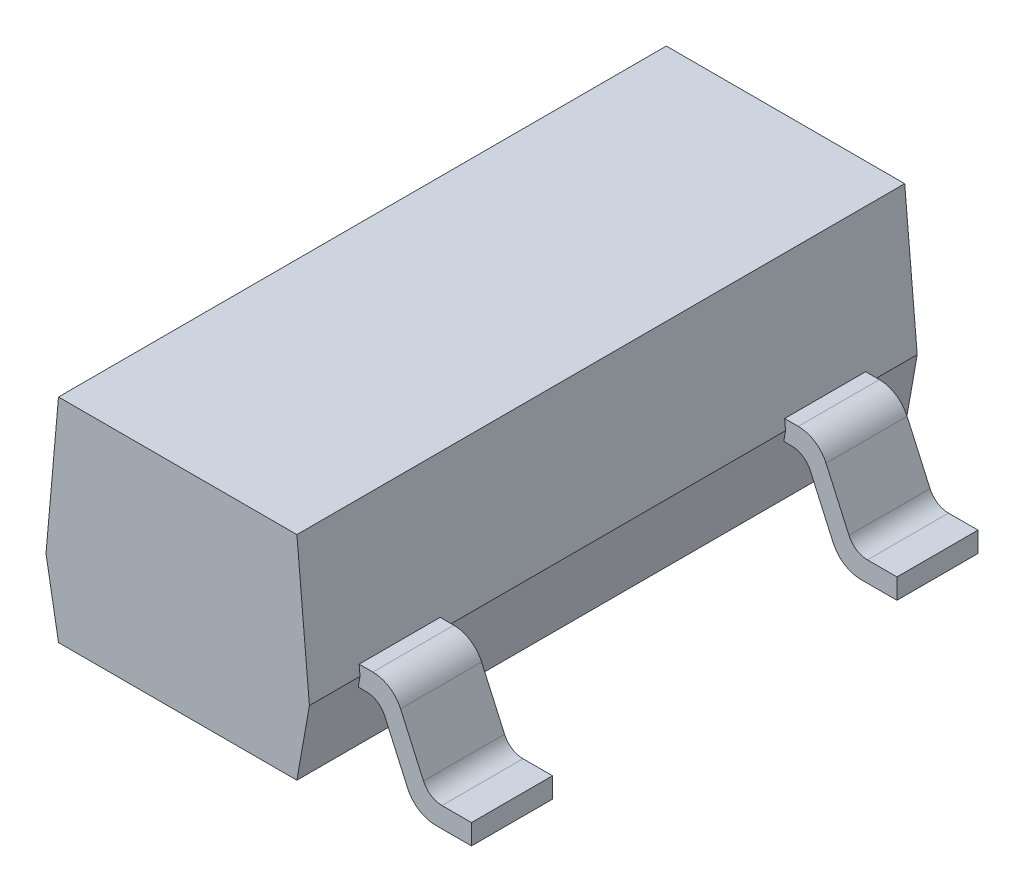
from build123d import *

# Parameters (mm, degrees)
EXTRUDE1_DEPTH     = 1.5
EXTRUDE2_DEPTH     = 0.2
EXTRUDE5_DEPTH     = 0.2
EXTRUDE6_DEPTH     = 0.2
FILLET2_R          = 0.1
SKETCH14_W         = 0.020253164
SKETCH14_H         = 0.021265823
SKETCH14_W_2       = 0.020253165
CUT_EXTRUDE1_DEPTH = 0.01


with BuildPart() as part:
    # Sketch1 → Extrude1 (new body, symmetric)
    with BuildSketch(Plane.XY):
        Polygon((0.588285557, 0.525), (-0.588285557, 0.525), (-0.65, -0.175), (-0.588285557, -0.525), (0.588285557, -0.525), (0.65, -0.175), align=None)
    extrude(amount=EXTRUDE1_DEPTH, both=True)

    # Sketch2 → Extrude2 (add, symmetric)
    with BuildSketch(Plane.XY.offset(1.05)):
        with BuildLine():
            Line((0.713146135, -0.125), (0.5, -0.125))
            Line((0.5, -0.125), (0.5, -0.225))
            Line((0.5, -0.225), (0.745513278, -0.225))
            Line((0.745513278, -0.225), (0.885247563, -0.536408629))
            ThreePointArc((0.885247563, -0.536408629), (0.940588528, -0.600919209), (1.022101428, -0.625))
            Line((1.022101428, -0.625), (1.2, -0.625))
            Line((1.2, -0.625), (1.2, -0.525))
            Line((1.2, -0.525), (1.05446857, -0.525))
            ThreePointArc((1.05446857, -0.525), (1.000126637, -0.508946139), (0.96323266, -0.465939086))
            Line((0.96323266, -0.465939086), (0.85, -0.213591371))
            ThreePointArc((0.85, -0.213591371), (0.794659035, -0.149080791), (0.713146135, -0.125))
        make_face()
    extrude(amount=EXTRUDE2_DEPTH, both=True)

    # Sketch12 → Extrude5 (add, symmetric)
    with BuildSketch(Plane.XY.offset(-1.05)):
        with BuildLine():
            Line((1.022101428, -0.625), (1.2, -0.625))
            Line((1.2, -0.625), (1.2, -0.525))
            Line((1.2, -0.525), (1.05446857, -0.525))
            ThreePointArc((1.05446857, -0.525), (1.000126637, -0.508946139), (0.96323266, -0.465939086))
            Line((0.96323266, -0.465939086), (0.85, -0.213591371))
            ThreePointArc((0.85, -0.213591371), (0.794659035, -0.149080791), (0.713146135, -0.125))
            Line((0.713146135, -0.125), (0.5, -0.125))
            Line((0.5, -0.125), (0.5, -0.225))
            Line((0.5, -0.225), (0.745513278, -0.225))
            Line((0.745513278, -0.225), (0.885247563, -0.536408629))
            ThreePointArc((0.885247563, -0.536408629), (0.940588528, -0.600919209), (1.022101428, -0.625))
        make_face()
    extrude(amount=EXTRUDE5_DEPTH, both=True)

    # Sketch13 → Extrude6 (add, symmetric)
    with BuildSketch(Plane.XY):
        with BuildLine():
            Line((-1.2, -0.625), (-1.022101428, -0.625))
            ThreePointArc((-1.022101428, -0.625), (-0.940588528, -0.600919209), (-0.885247563, -0.536408629))
            Line((-0.885247563, -0.536408629), (-0.745513278, -0.225))
            Line((-0.745513278, -0.225), (-0.5, -0.225))
            Line((-0.5, -0.225), (-0.5, -0.125))
            Line((-0.5, -0.125), (-0.713146135, -0.125))
            ThreePointArc((-0.713146135, -0.125), (-0.794659035, -0.149080791), (-0.85, -0.213591371))
            Line((-0.85, -0.213591371), (-0.96323266, -0.465939086))
            ThreePointArc((-0.96323266, -0.465939086), (-1.000126637, -0.508946139), (-1.05446857, -0.525))
            Line((-1.05446857, -0.525), (-1.2, -0.525))
            Line((-1.2, -0.525), (-1.2, -0.625))
        make_face()
    extrude(amount=EXTRUDE6_DEPTH, both=True)

    # Fillet2
    fillet2_edges = [part.edges().sort_by_distance(p)[0] for p in [
        (0.745513278, -0.225, 1.05),
        (0.745513278, -0.225, -1.05),
        (-0.745513278, -0.225, 0),
    ]]
    fillet(fillet2_edges, radius=FILLET2_R)

    # Sketch14 → Cut-Extrude1 (cut)
    with BuildSketch(Plane.XZ.offset(0.525)):
        Polygon((0.467126587, 1.30364904), (0.48589241, 1.363395875), (0.505686714, 1.363395875), (0.518819625, 1.323126888), (0.531240511, 1.363395875), (0.551825954, 1.363395875), (0.570417726, 1.30364904), (0.550275321, 1.30364904), (0.539879752, 1.344835749), (0.52674684, 1.30364904), (0.509547473, 1.30364904), (0.496493676, 1.344835749), (0.486240511, 1.30364904), align=None)
        Polygon((0.359784815, 1.30364904), (0.378550638, 1.363395875), (0.398344942, 1.363395875), (0.411477853, 1.323126888), (0.423898739, 1.363395875), (0.444484182, 1.363395875), (0.463075954, 1.30364904), (0.442933549, 1.30364904), (0.43253798, 1.344835749), (0.419405068, 1.30364904), (0.402205701, 1.30364904), (0.389151904, 1.344835749), (0.378898739, 1.30364904), align=None)
        Polygon((0.252443043, 1.30364904), (0.271208866, 1.363395875), (0.291003169, 1.363395875), (0.304136081, 1.323126888), (0.316556967, 1.363395875), (0.33714241, 1.363395875), (0.355734182, 1.30364904), (0.335591777, 1.30364904), (0.325196207, 1.344835749), (0.312063296, 1.30364904), (0.294863929, 1.30364904), (0.281810132, 1.344835749), (0.271556967, 1.30364904), align=None)
        with Locations((0.230164562, 1.352762964)):
            Rectangle(SKETCH14_W, SKETCH14_H)
        with BuildLine():
            add(Edge.make_bspline(
                [(0.137000005, 1.338459166), (0.137029227, 1.339436858), (0.137086611, 1.341356717), (0.13757394, 1.34416309), (0.13837036, 1.346821716), (0.13946183, 1.349351889), (0.140913021, 1.351716182), (0.142637031, 1.353971035), (0.144726563, 1.356038205), (0.147076192, 1.357989214), (0.149714534, 1.359735129), (0.152596631, 1.36125524), (0.155692887, 1.362555015), (0.159016104, 1.363620367), (0.162572566, 1.364412981), (0.166346787, 1.364991634), (0.170341466, 1.365370441), (0.173080337, 1.365403994), (0.174484182, 1.365421192)],
                knots=[0, 0, 0, 0, 0.907421153, 1.781872267, 2.635683434, 3.480115191, 4.332689235, 5.205575272, 6.109500117, 7.055808355, 8.037942167, 9.041423561, 10.07750834, 11.152467461, 12.277657752, 13.45734338, 14.696726425, 16, 16, 16, 16], degree=3))
            add(Edge.make_bspline(
                [(0.174484182, 1.365421192), (0.17609857, 1.36539938), (0.179225119, 1.365357137), (0.183759173, 1.365048838), (0.187969946, 1.364498479), (0.191888144, 1.363733214), (0.195571585, 1.362770586), (0.19911826, 1.361738071), (0.202543294, 1.360566407), (0.204761768, 1.359686298), (0.205860764, 1.359250306)],
                knots=[0, 0, 0, 0, 1.203182053, 2.33017619, 3.384818652, 4.366208123, 5.30340534, 6.221361684, 7.118890722, 8, 8, 8, 8], degree=3))
            Line((0.205860764, 1.359250306), (0.205860764, 1.340104736))
            Line((0.205860764, 1.340104736), (0.203582283, 1.340104736))
            add(Edge.make_bspline(
                [(0.203582283, 1.340104736), (0.202489833, 1.340969506), (0.200311345, 1.342693969), (0.196769779, 1.344908653), (0.193042569, 1.346807061), (0.189171854, 1.348393159), (0.185250759, 1.349653651), (0.181355505, 1.350555175), (0.177540319, 1.351146667), (0.175013662, 1.351211916), (0.173772157, 1.351243976)],
                knots=[0, 0, 0, 0, 1.030738938, 2.055426519, 3.085610749, 4.123842265, 5.148648843, 6.130724483, 7.081507926, 8, 8, 8, 8], degree=3))
            add(Edge.make_bspline(
                [(0.173772157, 1.351243976), (0.17342916, 1.351242936), (0.17269483, 1.351240708), (0.171519512, 1.351143656), (0.170194437, 1.351041381), (0.168769846, 1.350884489), (0.167340082, 1.350699574), (0.166011884, 1.3504224), (0.164811275, 1.350127079), (0.164085939, 1.349833266), (0.163740511, 1.349693344)],
                knots=[0, 0, 0, 0, 0.806537132, 1.726733348, 2.77251655, 3.932999672, 5.098049949, 6.161349231, 7.124375527, 8, 8, 8, 8], degree=3))
            add(Edge.make_bspline(
                [(0.163740511, 1.349693344), (0.163356922, 1.349510755), (0.162603088, 1.34915193), (0.161561064, 1.348500802), (0.160624676, 1.347785006), (0.159776114, 1.347015619), (0.159086197, 1.346085229), (0.158589269, 1.344965812), (0.158313612, 1.343646378), (0.158282355, 1.342706248), (0.158265828, 1.342209166)],
                knots=[0, 0, 0, 0, 1.02474257, 2.013837243, 2.958431669, 3.867978675, 4.769292696, 5.732237074, 6.800947934, 8, 8, 8, 8], degree=3))
            add(Edge.make_bspline(
                [(0.158265828, 1.342209166), (0.158290997, 1.341772473), (0.158340487, 1.340913806), (0.158805691, 1.339691063), (0.159512929, 1.338554954), (0.160536461, 1.337542685), (0.161827404, 1.336641795), (0.163372194, 1.335833184), (0.165191274, 1.335164579), (0.166501044, 1.334814281), (0.167189878, 1.334630052)],
                knots=[0, 0, 0, 0, 0.825427492, 1.623033598, 2.45033906, 3.348940377, 4.33183287, 5.428402891, 6.647546779, 8, 8, 8, 8], degree=3))
            add(Edge.make_bspline(
                [(0.167189878, 1.334630052), (0.168765271, 1.334273889), (0.17199344, 1.333544066), (0.176905291, 1.332594103), (0.181816253, 1.331613406), (0.184981258, 1.330641954), (0.186525321, 1.330168027)],
                knots=[0, 0, 0, 0, 0.976118991, 2.000185432, 3.024380873, 4, 4, 4, 4], degree=3))
            add(Edge.make_bspline(
                [(0.186525321, 1.330168027), (0.187355844, 1.329885049), (0.188972533, 1.329334205), (0.191291887, 1.328412087), (0.193406485, 1.327367979), (0.195372516, 1.326310349), (0.197126647, 1.325126303), (0.198722354, 1.323900095), (0.200124483, 1.322577851), (0.201345633, 1.321178258), (0.202419926, 1.319709168), (0.203342653, 1.318151455), (0.204111472, 1.316498295), (0.204770185, 1.314773978), (0.205259166, 1.312954349), (0.205597115, 1.311053216), (0.205835566, 1.309066427), (0.205852251, 1.307710958), (0.205860764, 1.307019293)],
                knots=[0, 0, 0, 0, 1.287376879, 2.505999703, 3.65855109, 4.746193839, 5.778582289, 6.760029101, 7.696159662, 8.601061861, 9.48181646, 10.363080883, 11.252765705, 12.153987336, 13.068239035, 14.012364187, 14.985753787, 16, 16, 16, 16], degree=3))
            add(Edge.make_bspline(
                [(0.205860764, 1.307019293), (0.205830924, 1.306094376), (0.205772199, 1.304274156), (0.205291039, 1.301610938), (0.20446983, 1.299091883), (0.203360743, 1.296689358), (0.201898748, 1.294437948), (0.20014505, 1.292295958), (0.198056802, 1.290301962), (0.19566854, 1.288463052), (0.193039062, 1.286800008), (0.190211858, 1.285330642), (0.187188777, 1.284125484), (0.184004869, 1.283100499), (0.180629355, 1.282338583), (0.177079779, 1.28176292), (0.173340689, 1.28143252), (0.17078756, 1.2813915), (0.169484182, 1.281370559)],
                knots=[0, 0, 0, 0, 0.894901293, 1.761149761, 2.608783409, 3.453876344, 4.314933854, 5.200038827, 6.12799933, 7.103249695, 8.113098521, 9.136064399, 10.182719798, 11.259667356, 12.370545059, 13.528828137, 14.738461593, 16, 16, 16, 16], degree=3))
            add(Edge.make_bspline(
                [(0.169484182, 1.281370559), (0.168149261, 1.281388473), (0.165481682, 1.281424271), (0.161496103, 1.281724247), (0.157530172, 1.282177448), (0.15363292, 1.282817011), (0.149886915, 1.283631136), (0.146353624, 1.284499902), (0.143090448, 1.285492214), (0.141031468, 1.28625545), (0.14003798, 1.286623723)],
                knots=[0, 0, 0, 0, 1.065379838, 2.128953261, 3.188461447, 4.250817766, 5.279613205, 6.247547721, 7.154416075, 8, 8, 8, 8], degree=3))
            Line((0.14003798, 1.286623723), (0.14003798, 1.304661698))
            Line((0.14003798, 1.304661698), (0.142300638, 1.304661698))
            add(Edge.make_bspline(
                [(0.142300638, 1.304661698), (0.143159005, 1.304021535), (0.14491439, 1.302712385), (0.147841392, 1.301043603), (0.15101264, 1.299483992), (0.154424561, 1.298106557), (0.158002594, 1.296970077), (0.161664631, 1.296146841), (0.165366282, 1.295635543), (0.167847555, 1.295577037), (0.169088613, 1.295547774)],
                knots=[0, 0, 0, 0, 0.89224925, 1.824673196, 2.804309561, 3.838364047, 4.890042674, 5.931526337, 6.965412421, 8, 8, 8, 8], degree=3))
            add(Edge.make_bspline(
                [(0.169088613, 1.295547774), (0.169964852, 1.295567142), (0.171716649, 1.295605862), (0.174336175, 1.295885265), (0.176924008, 1.296422659), (0.178558327, 1.297074128), (0.179373423, 1.29739904)],
                knots=[0, 0, 0, 0, 0.998993879, 1.997209027, 3.00113285, 4, 4, 4, 4], degree=3))
            add(Edge.make_bspline(
                [(0.179373423, 1.29739904), (0.179720206, 1.297560226), (0.180413542, 1.297882491), (0.181379144, 1.298500352), (0.182261787, 1.299244126), (0.183062592, 1.300086041), (0.183741036, 1.301021509), (0.184251164, 1.302037316), (0.18453982, 1.303126899), (0.184576489, 1.303874234), (0.184594942, 1.304250306)],
                knots=[0, 0, 0, 0, 1.005454979, 2.010239304, 3.005296729, 4.036100111, 5.060531193, 6.034954812, 7.011155677, 8, 8, 8, 8], degree=3))
            add(Edge.make_bspline(
                [(0.184594942, 1.304250306), (0.184567106, 1.30476065), (0.184513915, 1.305735873), (0.184033917, 1.30710683), (0.183235782, 1.308277319), (0.182313303, 1.309071714), (0.18141972, 1.309630722), (0.180587306, 1.310034913), (0.179627745, 1.310445652), (0.178525786, 1.310837009), (0.177297678, 1.311232247), (0.17593054, 1.311611982), (0.174424454, 1.31197163), (0.173371741, 1.312200551), (0.17282279, 1.312319926)],
                knots=[0, 0, 0, 0, 1.174343879, 2.244064321, 3.303704314, 4.407076671, 5.02483983, 5.732197225, 6.53898402, 7.431906431, 8.428480183, 9.514816237, 10.704066255, 12, 12, 12, 12], degree=3))
            add(Edge.make_bspline(
                [(0.17282279, 1.312319926), (0.17135669, 1.312621302), (0.168476128, 1.313213439), (0.164152068, 1.314088877), (0.159757624, 1.315138891), (0.156821184, 1.31604226), (0.155291144, 1.316512964)],
                knots=[0, 0, 0, 0, 0.995788186, 1.956503735, 2.935230479, 4, 4, 4, 4], degree=3))
            add(Edge.make_bspline(
                [(0.155291144, 1.316512964), (0.154533899, 1.316768357), (0.153052605, 1.317267947), (0.150940127, 1.318137002), (0.148982388, 1.319076087), (0.147169081, 1.320069663), (0.145508788, 1.32114361), (0.143999756, 1.322283876), (0.142641391, 1.323487702), (0.141450392, 1.324780278), (0.140387386, 1.326148557), (0.139497511, 1.327629047), (0.138701042, 1.32918387), (0.138098519, 1.330858625), (0.137598911, 1.332617447), (0.137261517, 1.334482995), (0.137026027, 1.336438369), (0.137008776, 1.337778048), (0.137000005, 1.338459166)],
                knots=[0, 0, 0, 0, 1.237326419, 2.420410185, 3.534642089, 4.598489486, 5.620241961, 6.59385002, 7.525152549, 8.426792174, 9.312230456, 10.203151844, 11.098070343, 12.012931196, 12.954244379, 13.926618287, 14.945853925, 16, 16, 16, 16], degree=3))
        make_face()
        with BuildLine():
            Line((0.063075954, 1.363395875), (0.082316461, 1.363395875))
            Line((0.082316461, 1.363395875), (0.082316461, 1.357130052))
            add(Edge.make_bspline(
                [(0.082316461, 1.357130052), (0.083191016, 1.357777088), (0.084877145, 1.359024564), (0.087416792, 1.360686213), (0.089831432, 1.362113751), (0.092175714, 1.363332245), (0.094580735, 1.364301982), (0.097171243, 1.364956686), (0.09997252, 1.365358865), (0.101914176, 1.365399954), (0.102917726, 1.365421192)],
                knots=[0, 0, 0, 0, 1.150945962, 2.219006967, 3.209666795, 4.118194914, 5.012574058, 5.946577101, 6.93868214, 8, 8, 8, 8], degree=3))
            add(Edge.make_bspline(
                [(0.102917726, 1.365421192), (0.103730746, 1.365402833), (0.105313931, 1.365367084), (0.107616571, 1.365093708), (0.109778144, 1.364654981), (0.111801213, 1.364040256), (0.113680973, 1.363237831), (0.115395917, 1.362220523), (0.116997979, 1.361074352), (0.118423536, 1.35970926), (0.119715973, 1.358190925), (0.12082203, 1.356484997), (0.121764194, 1.354618646), (0.122517074, 1.352577166), (0.123121145, 1.350370522), (0.123540291, 1.347987124), (0.123796765, 1.345437422), (0.123822316, 1.343681318), (0.123835448, 1.342778787)],
                knots=[0, 0, 0, 0, 1.108959949, 2.159465255, 3.158589008, 4.114545495, 5.039534357, 5.93921201, 6.830099133, 7.720870013, 8.624681761, 9.544731627, 10.487599671, 11.471264588, 12.508152322, 13.604835107, 14.769030043, 16, 16, 16, 16], degree=3))
            Line((0.123835448, 1.342778787), (0.123835448, 1.30364904))
            Line((0.123835448, 1.30364904), (0.104594942, 1.30364904))
            Line((0.104594942, 1.30364904), (0.104594942, 1.333712331))
            add(Edge.make_bspline(
                [(0.104594942, 1.333712331), (0.104593633, 1.334445508), (0.104591129, 1.33584888), (0.104525258, 1.337853525), (0.104428537, 1.339668063), (0.104317573, 1.341301686), (0.10411516, 1.342779087), (0.103812993, 1.344112016), (0.103436332, 1.345327697), (0.103064877, 1.346053059), (0.102886081, 1.346402204)],
                knots=[0, 0, 0, 0, 1.361401701, 2.605856924, 3.723918663, 4.735739235, 5.645738665, 6.489217889, 7.27279937, 8, 8, 8, 8], degree=3))
            add(Edge.make_bspline(
                [(0.102886081, 1.346402204), (0.102702074, 1.346721169), (0.102340333, 1.347348226), (0.101604121, 1.348153275), (0.100741047, 1.348828275), (0.099719284, 1.349354756), (0.098527631, 1.349747158), (0.097150944, 1.350051615), (0.09555755, 1.350189117), (0.094431576, 1.35021671), (0.093835448, 1.350231318)],
                knots=[0, 0, 0, 0, 0.849004071, 1.669068917, 2.503060811, 3.370079215, 4.310762265, 5.396376419, 6.621555549, 8, 8, 8, 8], degree=3))
            add(Edge.make_bspline(
                [(0.093835448, 1.350231318), (0.093402694, 1.350215447), (0.092513561, 1.350182838), (0.091139599, 1.350029605), (0.089708191, 1.349710278), (0.087693256, 1.349194322), (0.085161088, 1.348239239), (0.083273461, 1.347156721), (0.082316461, 1.3466079)],
                knots=[0, 0, 0, 0, 0.638062719, 1.310959128, 2.033463623, 2.796942592, 4.376095945, 6, 6, 6, 6], degree=3))
            Line((0.082316461, 1.3466079), (0.082316461, 1.30364904))
            Line((0.082316461, 1.30364904), (0.063075954, 1.30364904))
            Line((0.063075954, 1.30364904), (0.063075954, 1.363395875))
        make_face()
        with BuildLine():
            Line((-0.014898729, 1.363395875), (0.004341777, 1.363395875))
            Line((0.004341777, 1.363395875), (0.004341777, 1.333332584))
            add(Edge.make_bspline(
                [(0.004341777, 1.333332584), (0.004361782, 1.332108592), (0.00440176, 1.329662599), (0.004623, 1.326652124), (0.00493059, 1.324378892), (0.005224621, 1.322913621), (0.005570118, 1.321675128), (0.005899927, 1.320966519), (0.006050638, 1.320642711)],
                knots=[0, 0, 0, 0, 1.709111167, 3.415443484, 4.21113913, 4.910175115, 5.501990373, 6, 6, 6, 6], degree=3))
            add(Edge.make_bspline(
                [(0.006050638, 1.320642711), (0.006246207, 1.32032426), (0.006629646, 1.319699894), (0.007379527, 1.318889592), (0.008254554, 1.318226098), (0.009271495, 1.317682524), (0.010461982, 1.317299174), (0.011841116, 1.317016971), (0.013425264, 1.316848527), (0.014552326, 1.316825685), (0.015148739, 1.316813597)],
                knots=[0, 0, 0, 0, 0.860202684, 1.686548532, 2.528236983, 3.382486038, 4.33249885, 5.401154041, 6.624757403, 8, 8, 8, 8], degree=3))
            add(Edge.make_bspline(
                [(0.015148739, 1.316813597), (0.01605345, 1.316861677), (0.017899607, 1.31695979), (0.020199854, 1.317493123), (0.022053725, 1.318181095), (0.023539898, 1.318781443), (0.025066076, 1.319560724), (0.02608971, 1.320137877), (0.026620258, 1.320437014)],
                knots=[0, 0, 0, 0, 1.33818541, 2.730705359, 3.468371228, 4.262126284, 5.099261778, 6, 6, 6, 6], degree=3))
            Line((0.026620258, 1.320437014), (0.026620258, 1.363395875))
            Line((0.026620258, 1.363395875), (0.045860764, 1.363395875))
            Line((0.045860764, 1.363395875), (0.045860764, 1.30364904))
            Line((0.045860764, 1.30364904), (0.026620258, 1.30364904))
            Line((0.026620258, 1.30364904), (0.026620258, 1.309914863))
            add(Edge.make_bspline(
                [(0.026620258, 1.309914863), (0.025774333, 1.309269941), (0.024127689, 1.308014564), (0.021584299, 1.306382227), (0.019117181, 1.304943212), (0.016674773, 1.303732958), (0.014182809, 1.302767539), (0.011572602, 1.302118747), (0.008839477, 1.301683705), (0.006970105, 1.30164395), (0.006018992, 1.301623723)],
                knots=[0, 0, 0, 0, 1.126119141, 2.192057864, 3.198061997, 4.149848529, 5.076251285, 6.021887753, 6.99356175, 8, 8, 8, 8], degree=3))
            add(Edge.make_bspline(
                [(0.006018992, 1.301623723), (0.00522198, 1.301644044), (0.003666071, 1.301683712), (0.001398192, 1.301931354), (-0.000738694, 1.302372332), (-0.002733401, 1.303009018), (-0.00460195, 1.303802105), (-0.006340888, 1.304765288), (-0.007929567, 1.305935913), (-0.009392089, 1.307263864), (-0.010703369, 1.308776902), (-0.011820896, 1.310480405), (-0.012784386, 1.312349941), (-0.013543798, 1.314400051), (-0.014176857, 1.316613068), (-0.014580668, 1.319011972), (-0.01486679, 1.32157988), (-0.01488787, 1.3233528), (-0.014898729, 1.324266128)],
                knots=[0, 0, 0, 0, 1.08828964, 2.12453497, 3.110382522, 4.062402335, 4.978696626, 5.878225494, 6.769849763, 7.667011675, 8.57076823, 9.495541561, 10.442454184, 11.436213583, 12.475881554, 13.580560132, 14.753614518, 16, 16, 16, 16], degree=3))
            Line((-0.014898729, 1.324266128), (-0.014898729, 1.363395875))
        make_face()
        Polygon((-0.090848096, 1.363395875), (-0.033126577, 1.363395875), (-0.033126577, 1.283395875), (-0.053379742, 1.283395875), (-0.053379742, 1.348206002), (-0.090848096, 1.348206002), align=None)
        Polygon((-0.160721514, 1.363395875), (-0.102999995, 1.363395875), (-0.102999995, 1.283395875), (-0.160721514, 1.283395875), (-0.160721514, 1.298585749), (-0.12325316, 1.298585749), (-0.12325316, 1.312762964), (-0.157683539, 1.312762964), (-0.157683539, 1.327952837), (-0.12325316, 1.327952837), (-0.12325316, 1.348206002), (-0.160721514, 1.348206002), align=None)
        with BuildLine():
            add(Edge.make_bspline(
                [(-0.253886071, 1.323474989), (-0.253870619, 1.32439314), (-0.253840017, 1.326211449), (-0.253603864, 1.328903294), (-0.253183044, 1.331515835), (-0.252639699, 1.334063234), (-0.251901694, 1.336526376), (-0.251036323, 1.338932437), (-0.249988606, 1.341256832), (-0.248784724, 1.34349798), (-0.247465147, 1.345635662), (-0.246045347, 1.347651829), (-0.244568724, 1.349558403), (-0.242977274, 1.351314318), (-0.241313928, 1.352947934), (-0.239573506, 1.354460585), (-0.237729454, 1.35582333), (-0.236443724, 1.356641638), (-0.235800628, 1.357050938)],
                knots=[0, 0, 0, 0, 1.105570398, 2.18947457, 3.250358341, 4.290584537, 5.323553275, 6.344225964, 7.367641686, 8.3905646, 9.405808457, 10.390761353, 11.358902336, 12.307789878, 13.241960776, 14.165076779, 15.082208636, 16, 16, 16, 16], degree=3))
            add(Edge.make_bspline(
                [(-0.235800628, 1.357050938), (-0.234809278, 1.357620795), (-0.232821521, 1.358763417), (-0.229633954, 1.360096088), (-0.226336667, 1.361227467), (-0.222849322, 1.362038219), (-0.219138345, 1.362654087), (-0.215134497, 1.363092624), (-0.210808971, 1.363337026), (-0.207820977, 1.363375812), (-0.206275312, 1.363395875)],
                knots=[0, 0, 0, 0, 0.896321744, 1.797216976, 2.705381885, 3.628777036, 4.602292017, 5.655629376, 6.787275635, 8, 8, 8, 8], degree=3))
            Line((-0.206275312, 1.363395875), (-0.177936704, 1.363395875))
            Line((-0.177936704, 1.363395875), (-0.177936704, 1.283395875))
            Line((-0.177936704, 1.283395875), (-0.207082274, 1.283395875))
            add(Edge.make_bspline(
                [(-0.207082274, 1.283395875), (-0.20866523, 1.283409323), (-0.211718558, 1.283435263), (-0.216132411, 1.283767205), (-0.220214282, 1.284251815), (-0.223965946, 1.284967164), (-0.227407906, 1.285858829), (-0.230541739, 1.286969654), (-0.233434725, 1.288163747), (-0.235177554, 1.289183391), (-0.236022147, 1.289677521)],
                knots=[0, 0, 0, 0, 1.267083275, 2.444046388, 3.541868212, 4.55639609, 5.499737919, 6.385160515, 7.217431253, 8, 8, 8, 8], degree=3))
            add(Edge.make_bspline(
                [(-0.236022147, 1.289677521), (-0.23670291, 1.290106753), (-0.238056609, 1.290960284), (-0.239977581, 1.292385766), (-0.241761123, 1.293950627), (-0.243463925, 1.295592082), (-0.245047779, 1.297354392), (-0.246522339, 1.299225358), (-0.247885393, 1.301207833), (-0.249131763, 1.303295408), (-0.250268415, 1.30547945), (-0.25121986, 1.307777897), (-0.252059339, 1.310160721), (-0.252703768, 1.312647891), (-0.2532621, 1.31521416), (-0.253609887, 1.317887235), (-0.253839176, 1.320649226), (-0.253870308, 1.322525137), (-0.253886071, 1.323474989)],
                knots=[0, 0, 0, 0, 0.964065863, 1.917049184, 2.86229036, 3.805247319, 4.749389377, 5.698846072, 6.657678277, 7.629829384, 8.610569287, 9.604676042, 10.607940105, 11.6349849, 12.681042988, 13.752616828, 14.862056989, 16, 16, 16, 16], degree=3))
        make_face()
        with BuildLine():
            add(Edge.make_bspline(
                [(-0.232620248, 1.323348407), (-0.232585606, 1.322085663), (-0.232518716, 1.319647423), (-0.2319544, 1.316130908), (-0.231043001, 1.312896548), (-0.229972847, 1.310406615), (-0.228902933, 1.308587961), (-0.228000914, 1.307309345), (-0.227001182, 1.306097985), (-0.225888694, 1.304970913), (-0.224660547, 1.303925284), (-0.22333154, 1.302942155), (-0.221891507, 1.302039239), (-0.220873082, 1.301511234), (-0.22035759, 1.301243976)],
                knots=[0, 0, 0, 0, 1.694683197, 3.272273219, 4.767406206, 6.197615014, 6.895990032, 7.597410435, 8.296503208, 9.002591366, 9.720792421, 10.460154445, 11.220583224, 12, 12, 12, 12], degree=3))
            add(Edge.make_bspline(
                [(-0.22035759, 1.301243976), (-0.219817642, 1.300998765), (-0.218747427, 1.300512739), (-0.217091207, 1.29992547), (-0.215417046, 1.299475608), (-0.213661664, 1.299097669), (-0.211680256, 1.298875961), (-0.209342263, 1.29870582), (-0.206576925, 1.298596278), (-0.204587648, 1.298589421), (-0.203522147, 1.298585749)],
                knots=[0, 0, 0, 0, 0.826913061, 1.638999358, 2.447478739, 3.243919028, 4.140906711, 5.225381046, 6.513851968, 8, 8, 8, 8], degree=3))
            Line((-0.203522147, 1.298585749), (-0.198189868, 1.298585749))
            Line((-0.198189868, 1.298585749), (-0.198189868, 1.348206002))
            Line((-0.198189868, 1.348206002), (-0.203522147, 1.348206002))
            add(Edge.make_bspline(
                [(-0.203522147, 1.348206002), (-0.2041287, 1.348201965), (-0.205299688, 1.348194172), (-0.206992851, 1.34816289), (-0.20856466, 1.348114637), (-0.210010541, 1.348057163), (-0.21133545, 1.34796524), (-0.212525717, 1.347830363), (-0.213599598, 1.347714853), (-0.214853705, 1.347501157), (-0.216336224, 1.347167993), (-0.218065237, 1.34662552), (-0.219777663, 1.345945185), (-0.220888522, 1.345397214), (-0.221449362, 1.345120559)],
                knots=[0, 0, 0, 0, 1.186775798, 2.291144404, 3.313233901, 4.263515562, 5.122260739, 5.910868134, 6.60717912, 7.234883681, 8.398964994, 9.577230746, 10.776813768, 12, 12, 12, 12], degree=3))
            add(Edge.make_bspline(
                [(-0.221449362, 1.345120559), (-0.221916333, 1.344845778), (-0.222834683, 1.344305391), (-0.224149998, 1.3434207), (-0.22533939, 1.342432701), (-0.226464239, 1.341406222), (-0.227466533, 1.340293859), (-0.228405167, 1.339133475), (-0.229213372, 1.337883561), (-0.230209368, 1.336128737), (-0.231185153, 1.333702041), (-0.232017761, 1.330528807), (-0.232526973, 1.327040799), (-0.23258836, 1.324610733), (-0.232620248, 1.323348407)],
                knots=[0, 0, 0, 0, 0.755109416, 1.485004392, 2.205961541, 2.908125208, 3.605307969, 4.290649036, 4.985852759, 5.676964147, 7.100721462, 8.614478074, 10.241350405, 12, 12, 12, 12], degree=3))
        make_face(mode=Mode.SUBTRACT)
        with Locations((-0.279202526, 1.352762964)):
            Rectangle(SKETCH14_W_2, SKETCH14_H)
        with BuildLine():
            add(Edge.make_bspline(
                [(-0.338917717, 1.365421192), (-0.337645632, 1.365403731), (-0.335148734, 1.365369457), (-0.331491579, 1.364988096), (-0.327999736, 1.364413322), (-0.324681642, 1.363598785), (-0.321556392, 1.362513711), (-0.31861155, 1.361219299), (-0.31590006, 1.359605055), (-0.314249076, 1.358343501), (-0.31342721, 1.357715495)],
                knots=[0, 0, 0, 0, 1.123606455, 2.205459211, 3.245124445, 4.248821949, 5.220056174, 6.165006393, 7.086533249, 8, 8, 8, 8], degree=3))
            add(Edge.make_bspline(
                [(-0.31342721, 1.357715495), (-0.312665812, 1.357031676), (-0.311145961, 1.355666682), (-0.309173214, 1.35328954), (-0.307474746, 1.350663105), (-0.306046303, 1.347781327), (-0.304901565, 1.344647944), (-0.304083058, 1.341252214), (-0.303587661, 1.33760359), (-0.303533929, 1.335085243), (-0.303506324, 1.333791445)],
                knots=[0, 0, 0, 0, 0.916457077, 1.82937027, 2.759194969, 3.714948755, 4.706655623, 5.743329475, 6.840637961, 8, 8, 8, 8], degree=3))
            add(Edge.make_bspline(
                [(-0.303506324, 1.333791445), (-0.303537333, 1.332428863), (-0.303597431, 1.329787999), (-0.304128439, 1.325970249), (-0.304984128, 1.322436104), (-0.306214175, 1.319194578), (-0.307758528, 1.316240025), (-0.309570123, 1.313542557), (-0.311666543, 1.311108218), (-0.313272254, 1.309711866), (-0.314075944, 1.309012964)],
                knots=[0, 0, 0, 0, 1.171797512, 2.271099083, 3.308930235, 4.294129479, 5.24602549, 6.17106565, 7.084581485, 8, 8, 8, 8], degree=3))
            add(Edge.make_bspline(
                [(-0.314075944, 1.309012964), (-0.314896675, 1.308398195), (-0.31654805, 1.307161231), (-0.319270326, 1.305639143), (-0.322172478, 1.304368587), (-0.325229866, 1.303347212), (-0.328409854, 1.302583518), (-0.331660698, 1.302029385), (-0.334975739, 1.30168644), (-0.337208043, 1.301644729), (-0.338332274, 1.301623723)],
                knots=[0, 0, 0, 0, 0.952046378, 1.915591786, 2.889970712, 3.892742799, 4.906722985, 5.925995921, 6.955492795, 8, 8, 8, 8], degree=3))
            add(Edge.make_bspline(
                [(-0.338332274, 1.301623723), (-0.339329717, 1.301636841), (-0.341291029, 1.301662636), (-0.344170101, 1.301927118), (-0.346936468, 1.302328668), (-0.349582003, 1.302919526), (-0.3521156, 1.30365682), (-0.354558912, 1.30448247), (-0.356926298, 1.305390654), (-0.358446813, 1.306098076), (-0.359202527, 1.306449673)],
                knots=[0, 0, 0, 0, 1.107549047, 2.177816721, 3.208424937, 4.210433793, 5.185680559, 6.13785309, 7.074491882, 8, 8, 8, 8], degree=3))
            Line((-0.359202527, 1.306449673), (-0.359202527, 1.322889546))
            Line((-0.359202527, 1.322889546), (-0.356528476, 1.322889546))
            add(Edge.make_bspline(
                [(-0.356528476, 1.322889546), (-0.356128014, 1.322556837), (-0.355259994, 1.321835675), (-0.353846529, 1.320678405), (-0.352110273, 1.319478173), (-0.350792649, 1.318762473), (-0.350088603, 1.318380052)],
                knots=[0, 0, 0, 0, 0.792743043, 1.718305972, 2.780820752, 4, 4, 4, 4], degree=3))
            add(Edge.make_bspline(
                [(-0.350088603, 1.318380052), (-0.349345454, 1.318029142), (-0.347820727, 1.317309173), (-0.345786161, 1.316607263), (-0.344023617, 1.316186968), (-0.342572689, 1.315974516), (-0.341025252, 1.315825029), (-0.339957135, 1.315809116), (-0.339408223, 1.315800938)],
                knots=[0, 0, 0, 0, 1.332360773, 2.733622135, 3.480580446, 4.268165618, 5.10999921, 6, 6, 6, 6], degree=3))
            add(Edge.make_bspline(
                [(-0.339408223, 1.315800938), (-0.338795712, 1.315816403), (-0.337608694, 1.315846373), (-0.3358804, 1.316070411), (-0.334260706, 1.316444885), (-0.332750275, 1.31698724), (-0.33134721, 1.317668653), (-0.330051191, 1.318501809), (-0.328856446, 1.319480427), (-0.327801293, 1.320633732), (-0.326847041, 1.321897524), (-0.326031699, 1.323284858), (-0.325301729, 1.324762126), (-0.32474578, 1.326365688), (-0.324297989, 1.328068708), (-0.323986846, 1.329879204), (-0.323793279, 1.331798812), (-0.323770945, 1.333115858), (-0.323759489, 1.333791445)],
                knots=[0, 0, 0, 0, 1.087372478, 2.107277257, 3.088614887, 4.033572876, 4.950837204, 5.852283781, 6.763600506, 7.684681617, 8.621202104, 9.570420019, 10.537986648, 11.542161979, 12.577980734, 13.661919757, 14.800668594, 16, 16, 16, 16], degree=3))
            add(Edge.make_bspline(
                [(-0.323759489, 1.333791445), (-0.323771308, 1.33448277), (-0.323794273, 1.33582598), (-0.323981085, 1.337779269), (-0.324313797, 1.339604414), (-0.324770796, 1.34130467), (-0.325350274, 1.342877484), (-0.326074368, 1.344315401), (-0.326903453, 1.345640847), (-0.327899099, 1.346810937), (-0.328990206, 1.347863994), (-0.33020212, 1.348772902), (-0.331529511, 1.349531418), (-0.332955255, 1.350174988), (-0.334501688, 1.350637707), (-0.336146917, 1.35098706), (-0.337898561, 1.351217905), (-0.339106845, 1.351235156), (-0.339724679, 1.351243976)],
                knots=[0, 0, 0, 0, 1.230336593, 2.390482092, 3.487897344, 4.52859895, 5.520747884, 6.465347575, 7.38981449, 8.296085817, 9.192433006, 10.084246191, 10.984321635, 11.908883871, 12.862027947, 13.850751296, 14.901019963, 16, 16, 16, 16], degree=3))
            add(Edge.make_bspline(
                [(-0.339724679, 1.351243976), (-0.340305291, 1.351236977), (-0.341437172, 1.351223331), (-0.343090772, 1.351055688), (-0.344656776, 1.350810271), (-0.34612329, 1.350458308), (-0.347485475, 1.350048267), (-0.348730543, 1.349589911), (-0.349860923, 1.34910741), (-0.350549955, 1.348733206), (-0.350879742, 1.348554103)],
                knots=[0, 0, 0, 0, 1.201052708, 2.34140671, 3.435973211, 4.479046096, 5.459661032, 6.378175262, 7.223757638, 8, 8, 8, 8], degree=3))
            add(Edge.make_bspline(
                [(-0.350879742, 1.348554103), (-0.351439906, 1.348210187), (-0.35252356, 1.347544874), (-0.353994542, 1.346423621), (-0.355310437, 1.345292213), (-0.356130047, 1.344527239), (-0.356528476, 1.344155369)],
                knots=[0, 0, 0, 0, 1.098601379, 2.125273733, 3.088655601, 4, 4, 4, 4], degree=3))
            Line((-0.356528476, 1.344155369), (-0.359202527, 1.344155369))
            Line((-0.359202527, 1.344155369), (-0.359202527, 1.360721825))
            add(Edge.make_bspline(
                [(-0.359202527, 1.360721825), (-0.358446215, 1.36107182), (-0.356933409, 1.361771895), (-0.354601746, 1.362694992), (-0.352211368, 1.363469521), (-0.349772669, 1.364191985), (-0.347235003, 1.364742674), (-0.344576579, 1.365137173), (-0.34179138, 1.365377903), (-0.339888668, 1.365406565), (-0.338917717, 1.365421192)],
                knots=[0, 0, 0, 0, 0.952012952, 1.904254716, 2.862729541, 3.822037426, 4.808956931, 5.82647221, 6.890850784, 8, 8, 8, 8], degree=3))
        make_face()
        with BuildLine():
            add(Edge.make_bspline(
                [(-0.433126577, 1.333554103), (-0.433106821, 1.334758028), (-0.433068311, 1.337104801), (-0.432636857, 1.340522233), (-0.431986633, 1.343751032), (-0.431048608, 1.346780798), (-0.429864294, 1.349626618), (-0.428383543, 1.352258452), (-0.426646739, 1.354701036), (-0.42465391, 1.356932944), (-0.422412948, 1.358931752), (-0.419953602, 1.360687954), (-0.41725454, 1.362138708), (-0.414363092, 1.36334838), (-0.41125537, 1.364283768), (-0.407931995, 1.364933942), (-0.404398287, 1.365362318), (-0.401967553, 1.36540124), (-0.400721514, 1.365421192)],
                knots=[0, 0, 0, 0, 1.120167703, 2.183507516, 3.201345984, 4.182878364, 5.131270247, 6.065524964, 6.98789854, 7.91635504, 8.84481154, 9.778033504, 10.722808862, 11.691211189, 12.691525459, 13.738229926, 14.840575679, 16, 16, 16, 16], degree=3))
            add(Edge.make_bspline(
                [(-0.400721514, 1.365421192), (-0.399475497, 1.365401174), (-0.397044805, 1.365362124), (-0.393510797, 1.364934659), (-0.390183521, 1.364280299), (-0.387072076, 1.363355418), (-0.384185079, 1.362134178), (-0.381489186, 1.36068854), (-0.379030173, 1.358931585), (-0.376788985, 1.356933032), (-0.37479673, 1.354700851), (-0.373057857, 1.352259104), (-0.371583926, 1.349622341), (-0.370369643, 1.346787905), (-0.369462984, 1.343747235), (-0.368804213, 1.340522881), (-0.368375247, 1.337104625), (-0.368336387, 1.334757968), (-0.368316451, 1.333554103)],
                knots=[0, 0, 0, 0, 1.15937715, 2.261678054, 3.308339936, 4.313313916, 5.277148057, 6.221884977, 7.155068972, 8.083487698, 9.011906424, 9.934242473, 10.868459181, 11.818729666, 12.798784262, 13.81658132, 14.879877871, 16, 16, 16, 16], degree=3))
            add(Edge.make_bspline(
                [(-0.368316451, 1.333554103), (-0.368336532, 1.332344957), (-0.368375767, 1.329982534), (-0.3688043, 1.326543537), (-0.36945787, 1.32329466), (-0.370390296, 1.320244619), (-0.371595318, 1.317394638), (-0.373072874, 1.314749687), (-0.374829478, 1.312312268), (-0.376837026, 1.310080137), (-0.379087238, 1.308084514), (-0.381557237, 1.30634203), (-0.384248069, 1.304894996), (-0.387128351, 1.303672784), (-0.39023848, 1.302766747), (-0.393547782, 1.302112223), (-0.397065768, 1.301681895), (-0.399480748, 1.301643467), (-0.400721514, 1.301623723)],
                knots=[0, 0, 0, 0, 1.123883205, 2.195836198, 3.217400301, 4.202580581, 5.156396106, 6.089661422, 7.013912723, 7.944661364, 8.875797629, 9.805201257, 10.748976071, 11.711828658, 12.709674189, 13.755270167, 14.846705509, 16, 16, 16, 16], degree=3))
            add(Edge.make_bspline(
                [(-0.400721514, 1.301623723), (-0.401978104, 1.301643501), (-0.404424636, 1.301682007), (-0.407979365, 1.302110969), (-0.411318437, 1.302761373), (-0.414437337, 1.30369449), (-0.417337937, 1.304903621), (-0.420025997, 1.306371347), (-0.422483043, 1.308132994), (-0.424712846, 1.310138718), (-0.426697039, 1.31238304), (-0.428432172, 1.314822738), (-0.429877946, 1.317478511), (-0.431063362, 1.320322406), (-0.432001101, 1.323357421), (-0.432657889, 1.326584706), (-0.433062681, 1.330004703), (-0.433104908, 1.332350407), (-0.433126577, 1.333554103)],
                knots=[0, 0, 0, 0, 1.167358552, 2.272800965, 3.322628764, 4.326027541, 5.29287265, 6.238482395, 7.166210353, 8.096447471, 9.020151799, 9.945039072, 10.873038967, 11.824425184, 12.804379233, 13.820580988, 14.881633558, 16, 16, 16, 16], degree=3))
        make_face()
        with BuildLine():
            add(Edge.make_bspline(
                [(-0.409360755, 1.348348407), (-0.409644757, 1.347948342), (-0.410222736, 1.347134162), (-0.410923382, 1.345770439), (-0.411546244, 1.344304477), (-0.412042623, 1.342682376), (-0.412429699, 1.340846285), (-0.412676462, 1.338728241), (-0.412860737, 1.336299926), (-0.412869021, 1.334577741), (-0.412873413, 1.333664863)],
                knots=[0, 0, 0, 0, 0.765001119, 1.556867793, 2.387180485, 3.249178546, 4.200309879, 5.312433676, 6.575401142, 8, 8, 8, 8], degree=3))
            add(Edge.make_bspline(
                [(-0.412873413, 1.333664863), (-0.412859226, 1.332804963), (-0.412832045, 1.33115749), (-0.412683418, 1.328789599), (-0.41240225, 1.326638), (-0.412007436, 1.324698234), (-0.411521365, 1.322960578), (-0.410933523, 1.321414715), (-0.410266773, 1.320043551), (-0.409718169, 1.319239454), (-0.409455691, 1.318854736)],
                knots=[0, 0, 0, 0, 1.337015307, 2.56157572, 3.686511827, 4.707709802, 5.636963675, 6.488272502, 7.276717686, 8, 8, 8, 8], degree=3))
            add(Edge.make_bspline(
                [(-0.409455691, 1.318854736), (-0.409185781, 1.318503464), (-0.408656289, 1.31781436), (-0.407716457, 1.316946449), (-0.406699241, 1.31623424), (-0.405607672, 1.315677454), (-0.404439521, 1.315292078), (-0.403237632, 1.315006887), (-0.401992686, 1.314826565), (-0.40114933, 1.314801165), (-0.400721514, 1.31478828)],
                knots=[0, 0, 0, 0, 1.058488312, 2.076474566, 3.046302828, 4.022760093, 4.996603884, 5.982315336, 6.976474174, 8, 8, 8, 8], degree=3))
            add(Edge.make_bspline(
                [(-0.400721514, 1.31478828), (-0.400299168, 1.314797037), (-0.399473075, 1.314814166), (-0.398270942, 1.314957911), (-0.397142184, 1.315193583), (-0.396070284, 1.315527929), (-0.395036705, 1.316004316), (-0.39404923, 1.316689456), (-0.39307648, 1.31754972), (-0.392485882, 1.318230135), (-0.39217721, 1.318585749)],
                knots=[0, 0, 0, 0, 1.041978199, 2.038073998, 2.982578265, 3.884042198, 4.804014415, 5.778706634, 6.839057036, 8, 8, 8, 8], degree=3))
            add(Edge.make_bspline(
                [(-0.39217721, 1.318585749), (-0.391910422, 1.318965449), (-0.391349107, 1.31976433), (-0.390642727, 1.321127946), (-0.390057644, 1.322697482), (-0.389503852, 1.324444475), (-0.389089241, 1.326421394), (-0.38876865, 1.328624016), (-0.388608078, 1.331067558), (-0.388582818, 1.332773332), (-0.388569615, 1.333664863)],
                knots=[0, 0, 0, 0, 0.706185926, 1.485796665, 2.33004681, 3.254820698, 4.274138656, 5.402098861, 6.642194297, 8, 8, 8, 8], degree=3))
            add(Edge.make_bspline(
                [(-0.388569615, 1.333664863), (-0.38857694, 1.33446683), (-0.388591124, 1.336019714), (-0.388750152, 1.338264864), (-0.389013445, 1.340347868), (-0.389393574, 1.342260372), (-0.389858177, 1.344011479), (-0.390443848, 1.345578045), (-0.391115438, 1.34697622), (-0.391671604, 1.347795165), (-0.391939868, 1.348190179)],
                knots=[0, 0, 0, 0, 1.27086383, 2.460826804, 3.565079772, 4.596261907, 5.549370831, 6.432852304, 7.244093885, 8, 8, 8, 8], degree=3))
            add(Edge.make_bspline(
                [(-0.391939868, 1.348190179), (-0.39221226, 1.348523471), (-0.392749298, 1.349180577), (-0.393669244, 1.350046303), (-0.394691191, 1.350739499), (-0.395780853, 1.351302818), (-0.39694784, 1.351724956), (-0.398184993, 1.352050751), (-0.399509206, 1.352216816), (-0.400415224, 1.352243139), (-0.400879742, 1.352256635)],
                knots=[0, 0, 0, 0, 1.011466313, 1.994169768, 2.957274081, 3.905656451, 4.870834188, 5.869371193, 6.907620549, 8, 8, 8, 8], degree=3))
            add(Edge.make_bspline(
                [(-0.400879742, 1.352256635), (-0.401680869, 1.352215315), (-0.403280978, 1.352132788), (-0.405209897, 1.351543341), (-0.406651249, 1.350861696), (-0.407652842, 1.350178128), (-0.408571992, 1.349343382), (-0.409095262, 1.348683309), (-0.409360755, 1.348348407)],
                knots=[0, 0, 0, 0, 1.484683483, 2.96539121, 3.705388955, 4.438554905, 5.207767564, 6, 6, 6, 6], degree=3))
        make_face(mode=Mode.SUBTRACT)
        with BuildLine():
            Line((-0.50603797, 1.320437014), (-0.50603797, 1.363395875))
            Line((-0.50603797, 1.363395875), (-0.486797463, 1.363395875))
            Line((-0.486797463, 1.363395875), (-0.486797463, 1.333111065))
            add(Edge.make_bspline(
                [(-0.486797463, 1.333111065), (-0.48679309, 1.332399037), (-0.4867847, 1.331032932), (-0.486758281, 1.329065241), (-0.486694064, 1.327266358), (-0.486608032, 1.325629399), (-0.486458477, 1.324141826), (-0.486209405, 1.322801958), (-0.485872208, 1.321597538), (-0.485545527, 1.32087678), (-0.485389236, 1.320531951)],
                knots=[0, 0, 0, 0, 1.339742217, 2.570446543, 3.702449567, 4.726327994, 5.654556215, 6.512888379, 7.288529137, 8, 8, 8, 8], degree=3))
            add(Edge.make_bspline(
                [(-0.485389236, 1.320531951), (-0.48522123, 1.320223783), (-0.484888201, 1.319612917), (-0.484194716, 1.318836797), (-0.483382463, 1.318193569), (-0.482451522, 1.317653112), (-0.481335507, 1.317285076), (-0.480049107, 1.316996159), (-0.478556762, 1.316854972), (-0.477499122, 1.316827908), (-0.476939868, 1.316813597)],
                knots=[0, 0, 0, 0, 0.859137151, 1.703023591, 2.531884144, 3.395689496, 4.329139829, 5.403231912, 6.626892925, 8, 8, 8, 8], degree=3))
            add(Edge.make_bspline(
                [(-0.476939868, 1.316813597), (-0.476469918, 1.316832018), (-0.475525776, 1.316869026), (-0.474122125, 1.317068548), (-0.472741376, 1.317444734), (-0.470966735, 1.318120204), (-0.468885355, 1.319110037), (-0.467304251, 1.320006252), (-0.466544299, 1.320437014)],
                knots=[0, 0, 0, 0, 0.759272211, 1.52539342, 2.28366165, 3.065252147, 4.589423829, 6, 6, 6, 6], degree=3))
            Line((-0.466544299, 1.320437014), (-0.466544299, 1.363395875))
            Line((-0.466544299, 1.363395875), (-0.447303793, 1.363395875))
            Line((-0.447303793, 1.363395875), (-0.447303793, 1.30364904))
            Line((-0.447303793, 1.30364904), (-0.466544299, 1.30364904))
            Line((-0.466544299, 1.30364904), (-0.466544299, 1.309914863))
            add(Edge.make_bspline(
                [(-0.466544299, 1.309914863), (-0.46736089, 1.309289293), (-0.468946379, 1.308074689), (-0.471363071, 1.306441673), (-0.47371849, 1.305011321), (-0.476040225, 1.303784805), (-0.478404503, 1.302803688), (-0.480875783, 1.30212888), (-0.48347063, 1.301704642), (-0.485245166, 1.301651024), (-0.486148729, 1.301623723)],
                knots=[0, 0, 0, 0, 1.13602934, 2.205708752, 3.219814904, 4.178719654, 5.103700513, 6.040802208, 7.002410817, 8, 8, 8, 8], degree=3))
            add(Edge.make_bspline(
                [(-0.486148729, 1.301623723), (-0.487111248, 1.301649262), (-0.488992425, 1.301699176), (-0.491723021, 1.302232588), (-0.494289641, 1.303042858), (-0.496669294, 1.304208495), (-0.498831839, 1.305699674), (-0.500751134, 1.307517166), (-0.502441583, 1.309635648), (-0.50331385, 1.311244701), (-0.503759489, 1.312066761)],
                knots=[0, 0, 0, 0, 1.06596181, 2.083348439, 3.072786094, 4.043114605, 5.009947443, 5.973893017, 6.964867644, 8, 8, 8, 8], degree=3))
            add(Edge.make_bspline(
                [(-0.503759489, 1.312066761), (-0.504705158, 1.311285194), (-0.506548085, 1.30976207), (-0.50939096, 1.307727913), (-0.512174285, 1.305924473), (-0.514926487, 1.304396702), (-0.517643008, 1.303160792), (-0.520346309, 1.302276311), (-0.523025334, 1.301729554), (-0.524811942, 1.301658593), (-0.525689868, 1.301623723)],
                knots=[0, 0, 0, 0, 1.188124574, 2.315425566, 3.384037189, 4.39937427, 5.362203716, 6.270239573, 7.150007311, 8, 8, 8, 8], degree=3))
            add(Edge.make_bspline(
                [(-0.525689868, 1.301623723), (-0.52647647, 1.301642432), (-0.528006986, 1.301678834), (-0.530233015, 1.301946948), (-0.53231002, 1.302403971), (-0.534249001, 1.303037863), (-0.536037753, 1.303860836), (-0.537688256, 1.304858579), (-0.539166722, 1.306066978), (-0.54052095, 1.30742593), (-0.541712265, 1.308975265), (-0.542739975, 1.310685703), (-0.543596673, 1.312563133), (-0.544308146, 1.31459089), (-0.544858663, 1.316784014), (-0.545250133, 1.319138536), (-0.54548887, 1.321650426), (-0.545517143, 1.323379513), (-0.545531641, 1.324266128)],
                knots=[0, 0, 0, 0, 1.099136554, 2.138625863, 3.127574945, 4.066908717, 4.983764051, 5.873707737, 6.754323387, 7.645578618, 8.549333854, 9.478432518, 10.428234329, 11.428300305, 12.477672891, 13.584002437, 14.761160362, 16, 16, 16, 16], degree=3))
            Line((-0.545531641, 1.324266128), (-0.545531641, 1.363395875))
            Line((-0.545531641, 1.363395875), (-0.526291134, 1.363395875))
            Line((-0.526291134, 1.363395875), (-0.526291134, 1.333111065))
            add(Edge.make_bspline(
                [(-0.526291134, 1.333111065), (-0.526286596, 1.33239377), (-0.526277885, 1.331017131), (-0.526253687, 1.329038797), (-0.526182849, 1.327235216), (-0.526117473, 1.325598134), (-0.525984766, 1.324121306), (-0.525751192, 1.322789988), (-0.525409446, 1.32160124), (-0.525095822, 1.320877321), (-0.524946198, 1.320531951)],
                knots=[0, 0, 0, 0, 1.350818449, 2.592504867, 3.725474742, 4.749698069, 5.67770978, 6.515438232, 7.29174147, 8, 8, 8, 8], degree=3))
            add(Edge.make_bspline(
                [(-0.524946198, 1.320531951), (-0.524783433, 1.320224068), (-0.524461183, 1.319614505), (-0.523782804, 1.31883274), (-0.522967857, 1.318189493), (-0.522023285, 1.317653845), (-0.520887543, 1.317282616), (-0.519584127, 1.316999891), (-0.518071742, 1.316853047), (-0.517003412, 1.31682732), (-0.516433539, 1.316813597)],
                knots=[0, 0, 0, 0, 0.846272708, 1.675499002, 2.498229298, 3.366836971, 4.305509618, 5.396757786, 6.611368595, 8, 8, 8, 8], degree=3))
            add(Edge.make_bspline(
                [(-0.516433539, 1.316813597), (-0.515632644, 1.31685114), (-0.514021596, 1.316926662), (-0.512036395, 1.317503226), (-0.510413441, 1.318148456), (-0.509066558, 1.31879903), (-0.507579584, 1.319546179), (-0.506567719, 1.320130894), (-0.50603797, 1.320437014)],
                knots=[0, 0, 0, 0, 1.291206289, 2.597335145, 3.312416795, 4.112753053, 5.011956018, 6, 6, 6, 6], degree=3))
        make_face()
    extrude(amount=-CUT_EXTRUDE1_DEPTH, mode=Mode.SUBTRACT)


solid = part.part
